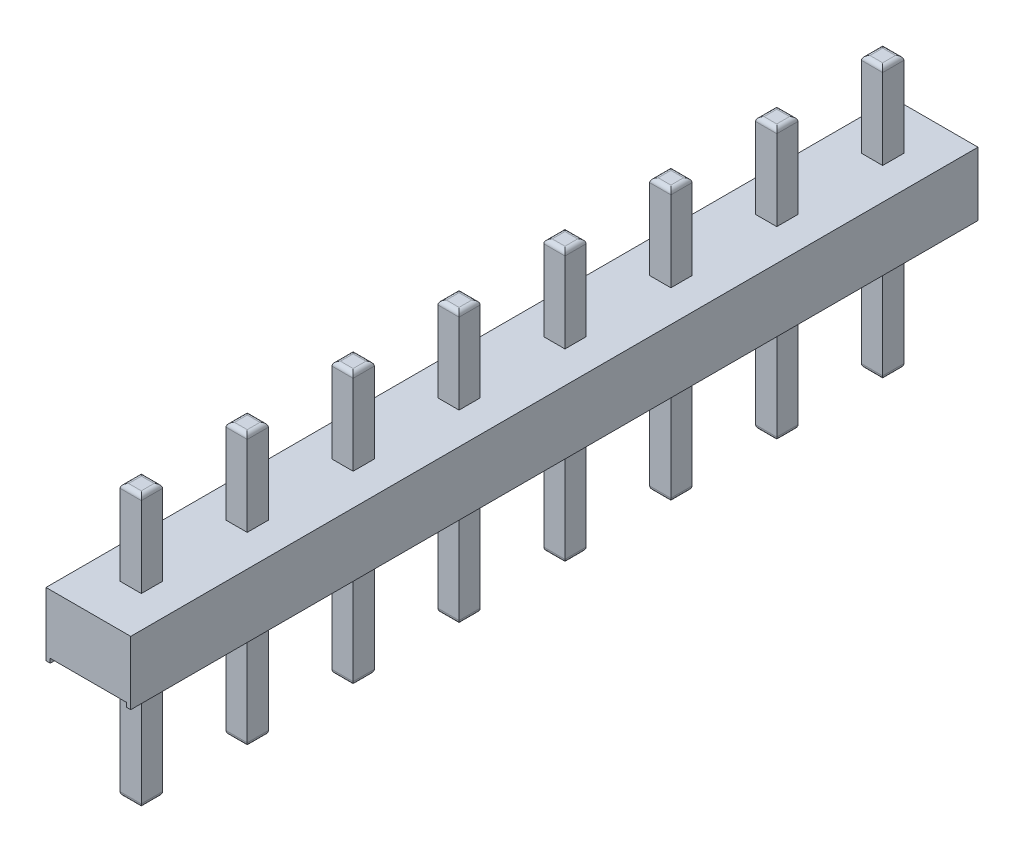
from build123d import *

# Parameters (mm, degrees)
BOSS_EXTRUDE1_DEPTH = 20
SKETCH2_W           = 0.5
SKETCH2_H           = 0.5
BOSS_EXTRUDE2_DEPTH = 2
SKETCH3_W           = 0.5
SKETCH3_H           = 0.5
BOSS_EXTRUDE3_DEPTH = 3
FILLET2_R           = 0.1


with BuildPart() as part:
    # Sketch1 → Boss-Extrude1 (new body)
    with BuildSketch(Plane.XY):
        Polygon((0.1, -1.5), (0.1, -1.399682434), (1.901861327, -1.399682434), (1.901861327, -1.5), (2, -1.5), (2, 0), (0, 0), (0, -1.5), align=None)
    extrude(amount=-BOSS_EXTRUDE1_DEPTH)

    # Sketch2 → Boss-Extrude2 (add)
    with BuildSketch(Plane(origin=(0, 0, 0), x_dir=(1, 0, 0), z_dir=(0, 1, 0))):
        with Locations((1, 3.75)):
            Rectangle(SKETCH2_W, SKETCH2_H)
        with Locations((1, 1.25)):
            Rectangle(SKETCH2_W, SKETCH2_H)
        with Locations((1, 6.25)):
            Rectangle(SKETCH2_W, SKETCH2_H)
        with Locations((1, 8.75)):
            Rectangle(SKETCH2_W, SKETCH2_H)
        with Locations((1, 11.25)):
            Rectangle(SKETCH2_W, SKETCH2_H)
        with Locations((1, 13.75)):
            Rectangle(SKETCH2_W, SKETCH2_H)
        with Locations((1, 16.25)):
            Rectangle(SKETCH2_W, SKETCH2_H)
        with Locations((1, 18.75)):
            Rectangle(SKETCH2_W, SKETCH2_H)
    extrude(amount=BOSS_EXTRUDE2_DEPTH)

    # Sketch3 → Boss-Extrude3 (add)
    with BuildSketch(Plane(origin=(0, -1.399682434, 0), x_dir=(-1, 0, 0), z_dir=(0, -1, 0))):
        with Locations((-1, 1.25)):
            Rectangle(SKETCH3_W, SKETCH3_H)
        with Locations((-1, 3.75)):
            Rectangle(SKETCH3_W, SKETCH3_H)
        with Locations((-1, 6.25)):
            Rectangle(SKETCH3_W, SKETCH3_H)
        with Locations((-1, 8.75)):
            Rectangle(SKETCH3_W, SKETCH3_H)
        with Locations((-1, 11.25)):
            Rectangle(SKETCH3_W, SKETCH3_H)
        with Locations((-1, 13.75)):
            Rectangle(SKETCH3_W, SKETCH3_H)
        with Locations((-1, 16.25)):
            Rectangle(SKETCH3_W, SKETCH3_H)
        with Locations((-1, 18.75)):
            Rectangle(SKETCH3_W, SKETCH3_H)
    extrude(amount=BOSS_EXTRUDE3_DEPTH)

    # Fillet2
    fillet2_edges = [part.edges().sort_by_distance(p)[0] for p in [
        (1, 2, -18.5),
        (1.25, 2, -18.75),
        (1, 2, -19),
        (0.75, 2, -18.75),
        (0.75, -4.399682434, -1.25),
        (1, -4.399682434, -1.5),
        (1.25, -4.399682434, -1.25),
        (1, -4.399682434, -1),
        (1, -4.399682434, -3.5),
        (0.75, -4.399682434, -3.75),
        (1, -4.399682434, -4),
        (1.25, -4.399682434, -3.75),
        (1, -4.399682434, -6),
        (0.75, -4.399682434, -6.25),
        (1, -4.399682434, -6.5),
        (1.25, -4.399682434, -6.25),
        (1, -4.399682434, -8.5),
        (0.75, -4.399682434, -8.75),
        (1, -4.399682434, -9),
        (1.25, -4.399682434, -8.75),
        (1, -4.399682434, -11),
        (0.75, -4.399682434, -11.25),
        (1, -4.399682434, -11.5),
        (1.25, -4.399682434, -11.25),
        (1, -4.399682434, -13.5),
        (0.75, -4.399682434, -13.75),
        (1, -4.399682434, -14),
        (1.25, -4.399682434, -13.75),
        (1, -4.399682434, -16),
        (0.75, -4.399682434, -16.25),
        (1, -4.399682434, -16.5),
        (1.25, -4.399682434, -16.25),
        (1, -4.399682434, -18.5),
        (0.75, -4.399682434, -18.75),
        (1, -4.399682434, -19),
        (1.25, -4.399682434, -18.75),
        (1.25, 2, -1.25),
        (1, 2, -1.5),
        (0.75, 2, -1.25),
        (1, 2, -1),
        (1, 2, -3.5),
        (1.25, 2, -3.75),
        (1, 2, -4),
        (0.75, 2, -3.75),
        (1, 2, -6),
        (1.25, 2, -6.25),
        (1, 2, -6.5),
        (0.75, 2, -6.25),
        (1, 2, -8.5),
        (1.25, 2, -8.75),
        (1, 2, -9),
        (0.75, 2, -8.75),
        (1, 2, -11),
        (1.25, 2, -11.25),
        (1, 2, -11.5),
        (0.75, 2, -11.25),
        (1, 2, -13.5),
        (1.25, 2, -13.75),
        (1, 2, -14),
        (0.75, 2, -13.75),
        (1, 2, -16),
        (1.25, 2, -16.25),
        (1, 2, -16.5),
        (0.75, 2, -16.25),
    ]]
    fillet(fillet2_edges, radius=FILLET2_R)


solid = part.part
